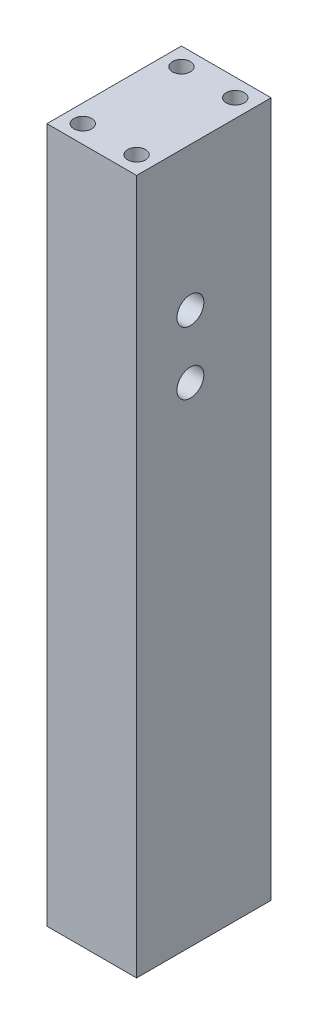
from build123d import *

# Parameters (mm, degrees)
SKETCH1_W           = 15
SKETCH1_H           = 77.5
BOSS_EXTRUDE1_DEPTH = 10
SKETCH3_R           = 1
CUT_EXTRUDE1_DEPTH  = 10
SKETCH4_R           = 1
CUT_EXTRUDE2_DEPTH  = 10
SKETCH5_R           = 1.5
CUT_EXTRUDE3_DEPTH  = 5


with BuildPart() as part:
    # Sketch1 → Boss-Extrude1 (new body)
    with BuildSketch(Plane(origin=(0, 0, 0), x_dir=(0, 0, -1), z_dir=(1, 0, 0))):
        with Locations((7.5, 38.75)):
            Rectangle(SKETCH1_W, SKETCH1_H)
    extrude(amount=BOSS_EXTRUDE1_DEPTH)

    # Sketch3 → Cut-Extrude1 (cut)
    with BuildSketch(Plane(origin=(0, 77.5, 0), x_dir=(1, 0, 0), z_dir=(0, 1, 0))):
        with Locations((2, 13)):
            Circle(SKETCH3_R)
        with Locations((8, 13)):
            Circle(SKETCH3_R)
        with Locations((8, 2)):
            Circle(SKETCH3_R)
        with Locations((2, 2)):
            Circle(SKETCH3_R)
    extrude(amount=-CUT_EXTRUDE1_DEPTH, mode=Mode.SUBTRACT)

    # Sketch4 → Cut-Extrude2 (cut)
    with BuildSketch(Plane(origin=(0, 0, 0), x_dir=(-1, 0, 0), z_dir=(0, -1, 0))):
        with Locations((-8, 2)):
            Circle(SKETCH4_R)
        with Locations((-8, 13)):
            Circle(SKETCH4_R)
        with Locations((-2, 13)):
            Circle(SKETCH4_R)
        with Locations((-2, 2)):
            Circle(SKETCH4_R)
    extrude(amount=-CUT_EXTRUDE2_DEPTH, mode=Mode.SUBTRACT)

    # Sketch5 → Cut-Extrude3 (cut)
    with BuildSketch(Plane(origin=(10, 0, 0), x_dir=(0, 0, -1), z_dir=(1, 0, 0))):
        with Locations((6, 61.5)):
            Circle(SKETCH5_R)
        with Locations((6, 54.5)):
            Circle(SKETCH5_R)
    extrude(amount=-CUT_EXTRUDE3_DEPTH, mode=Mode.SUBTRACT)


solid = part.part
